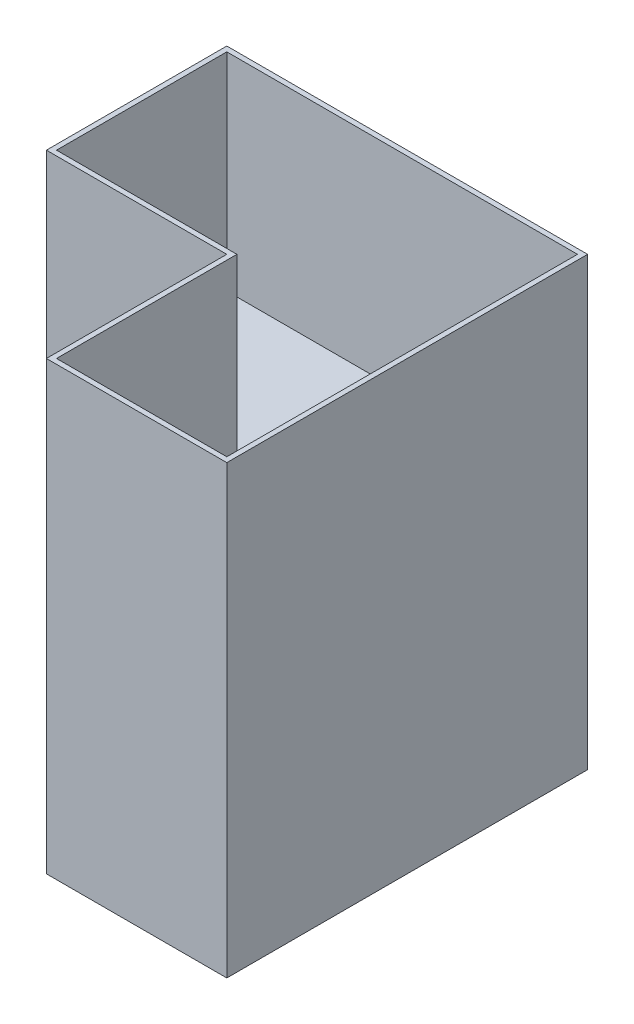
from build123d import *

# Parameters (mm, degrees)
BOSS_EXTRUDE1_DEPTH = 280
BOSS_EXTRUDE2_START = 140
BOSS_EXTRUDE2_DEPTH = 10


with BuildPart() as part:
    # Sketch1 → Boss-Extrude1 (new body)
    with BuildSketch(Plane(origin=(0, 0, 0), x_dir=(1, 0, 0), z_dir=(0, 1, 0))):
        Polygon((-116.35, -3.175), (-3.175, -3.175), (-3.175, -116.35), (110, -116.35), (110, 110), (-116.35, 110), align=None)
        Polygon((-113.175, 0), (0, 0), (0, -113.175), (106.825, -113.175), (106.825, 106.825), (-113.175, 106.825), align=None, mode=Mode.SUBTRACT)
    extrude(amount=BOSS_EXTRUDE1_DEPTH)

    # Sketch2 → Boss-Extrude2 (add)
    with BuildSketch(Plane(origin=(0, 0, 0), x_dir=(1, 0, 0), z_dir=(0, 1, 0)).offset(BOSS_EXTRUDE2_START)):
        Polygon((-113.175, 106.825), (-113.175, 0), (0, 0), (0, -113.175), (106.825, -113.175), (106.825, 106.825), align=None)
    extrude(amount=BOSS_EXTRUDE2_DEPTH)


solid = part.part
